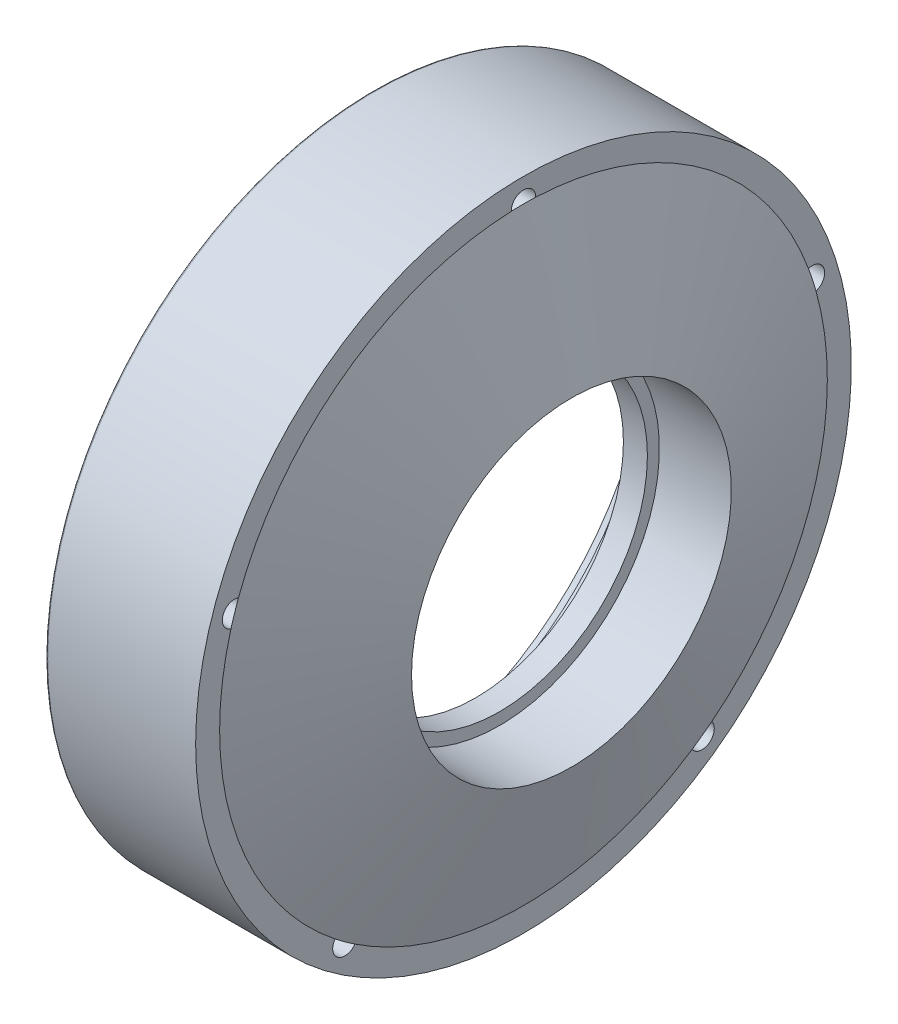
from build123d import *

# Parameters (mm, degrees)
SKETCH2_R          = 6.1
CUT_EXTRUDE1_DEPTH = 74.99773
CIRPATTERN1_COUNT  = 5
FILLET8_R          = 1


with BuildPart() as part:
    # Sketch1 → Revolve1 (revolve)
    with BuildSketch(Plane.XY):
        Polygon((74.997729735, 164), (74.997729735, 152), (98.99091894, 80), (62.997729735, 80), (62.997729735, 74), (50.997729735, 74), (50.997729735, 84), (43, 108), (43, 130), (10, 130), (10, 140), (0, 140), (0, 164), align=None)
    revolve(axis=Axis((0, 0, 0), (1, 0, 0)))

    # Sketch2 → Cut-Extrude1 (cut)
    with BuildSketch(Plane(origin=(74.997729735, 0, 0), x_dir=(0, 0, -1), z_dir=(1, 0, 0))):
        with Locations((0, 152)):
            Circle(SKETCH2_R)
    cut_extrude1 = extrude(amount=-CUT_EXTRUDE1_DEPTH, mode=Mode.SUBTRACT)

    # CirPattern1: Cut-Extrude1 ×5 about axis
    cirpattern1_axis = Axis((0, 0, 0), (1, 0, 0))
    for i in range(1, CIRPATTERN1_COUNT):
        add(cut_extrude1.rotate(cirpattern1_axis, i * 360 / CIRPATTERN1_COUNT), mode=Mode.SUBTRACT)

    # Fillet8
    fillet8_edges = [part.edges().sort_by_distance(p)[0] for p in [
        (0, -164, 0),
    ]]
    fillet(fillet8_edges, radius=FILLET8_R)


solid = part.part
